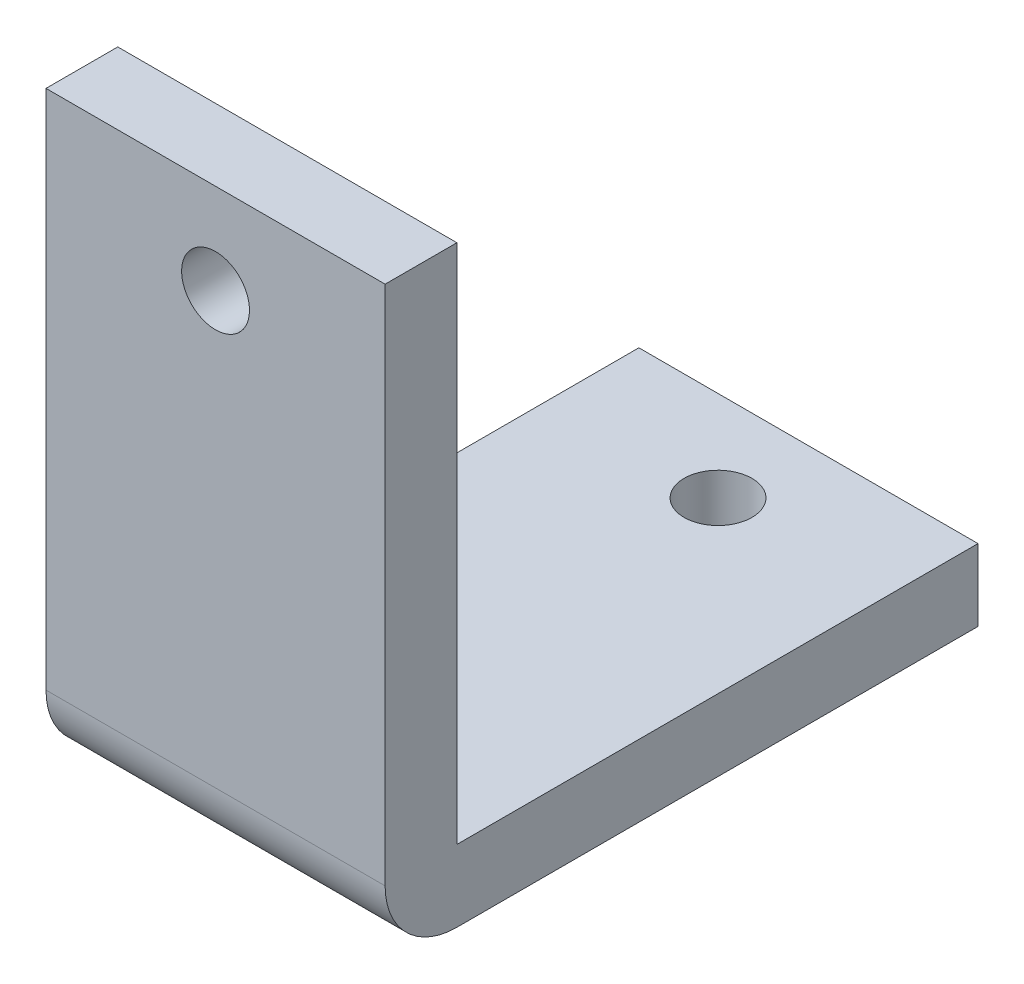
from build123d import *

# Parameters (mm, degrees)
BOSS_EXTRUDE1_DEPTH = 15
FILLET2_R           = 3.175
SKETCH7_R           = 1.5
CUT_EXTRUDE4_DEPTH  = 3.175
SKETCH8_R           = 1.5
CUT_EXTRUDE5_DEPTH  = 3.175


with BuildPart() as part:
    # Sketch1 → Boss-Extrude1 (new body)
    with BuildSketch(Plane(origin=(0, 0, 0), x_dir=(0, 0, -1), z_dir=(1, 0, 0))):
        Polygon((-3.175, 23.05), (-3.175, -3.175), (23.05, -3.175), (23.05, 0), (0, 0), (0, 23.05), align=None)
    extrude(amount=BOSS_EXTRUDE1_DEPTH)

    # Fillet2
    fillet2_edges = [part.edges().sort_by_distance(p)[0] for p in [
        (7.5, -3.175, 3.175),
    ]]
    fillet(fillet2_edges, radius=FILLET2_R)

    # Sketch7 → Cut-Extrude4 (cut)
    with BuildSketch(Plane.XY.offset(3.175)):
        with Locations((7.5, 19.05)):
            Circle(SKETCH7_R)
    extrude(amount=-CUT_EXTRUDE4_DEPTH, mode=Mode.SUBTRACT)

    # Sketch8 → Cut-Extrude5 (cut)
    with BuildSketch(Plane.XZ.offset(3.175)):
        with Locations((7.5, -19.05)):
            Circle(SKETCH8_R)
    extrude(amount=-CUT_EXTRUDE5_DEPTH, mode=Mode.SUBTRACT)


solid = part.part
